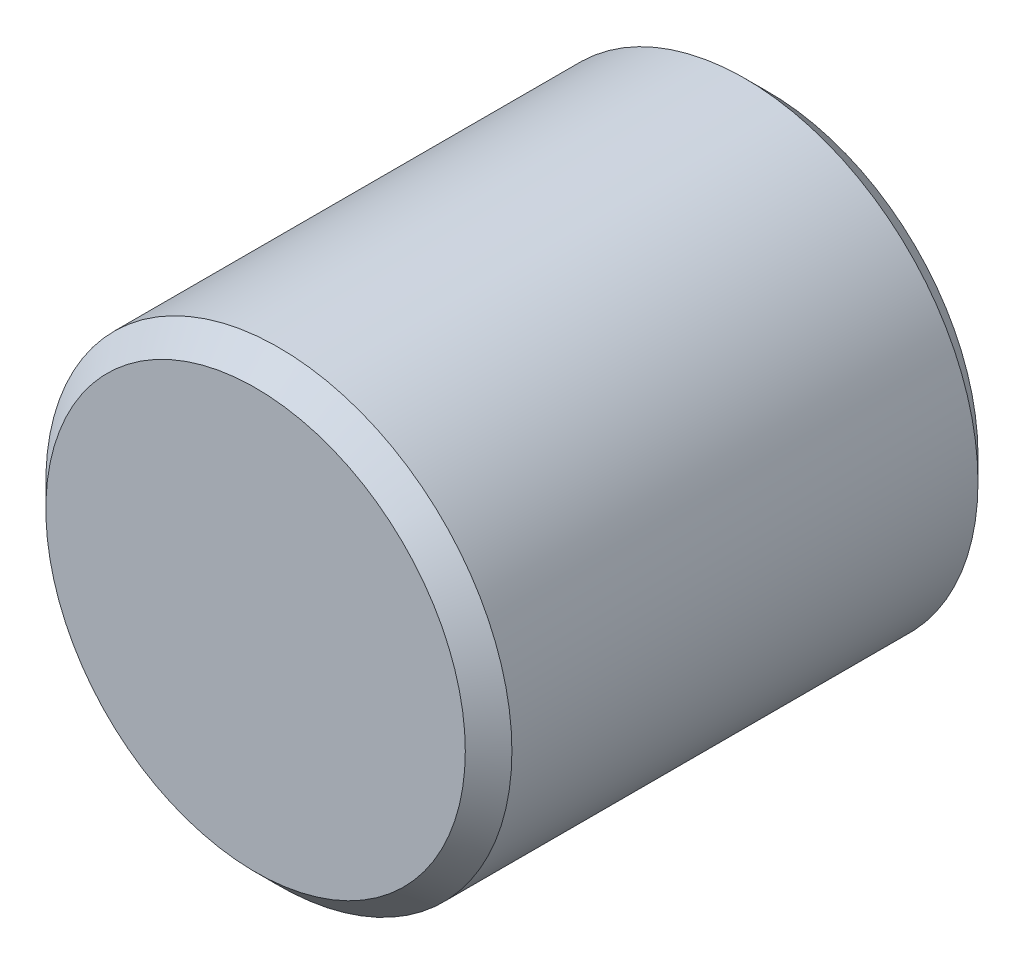
from build123d import *

# Parameters (mm, degrees)
SKETCH1_R             = 5
BOSS_EXTRUDE1_DEPTH   = 11
M3_TAPPED_HOLE1_D     = 2.5
M3_TAPPED_HOLE1_DEPTH = 7.5
M3_TAPPED_HOLE1_TIP   = 0.751075774
CHAMFER2_SIZE         = 0.5


with BuildPart() as part:
    # Sketch1 → Boss-Extrude1 (new body)
    with BuildSketch(Plane.XY):
        Circle(SKETCH1_R)
    extrude(amount=BOSS_EXTRUDE1_DEPTH)

    # M3 Tapped Hole1
    with Locations(Plane(origin=(0, 0, 0), x_dir=(-1, 0, 0), z_dir=(0, 0, -1))):
        with Locations((0, 0)):
            Hole(M3_TAPPED_HOLE1_D / 2, depth=M3_TAPPED_HOLE1_DEPTH)
            with Locations((0, 0, -(M3_TAPPED_HOLE1_DEPTH + M3_TAPPED_HOLE1_TIP / 2))):  # 118° drill point
                Cone(0, M3_TAPPED_HOLE1_D / 2, M3_TAPPED_HOLE1_TIP, mode=Mode.SUBTRACT)

    # Chamfer2
    chamfer2_edges = [part.edges().sort_by_distance(p)[0] for p in [
        (-5, 0, 0),
        (-5, 0, 11),
    ]]
    chamfer(chamfer2_edges, length=CHAMFER2_SIZE)


solid = part.part
